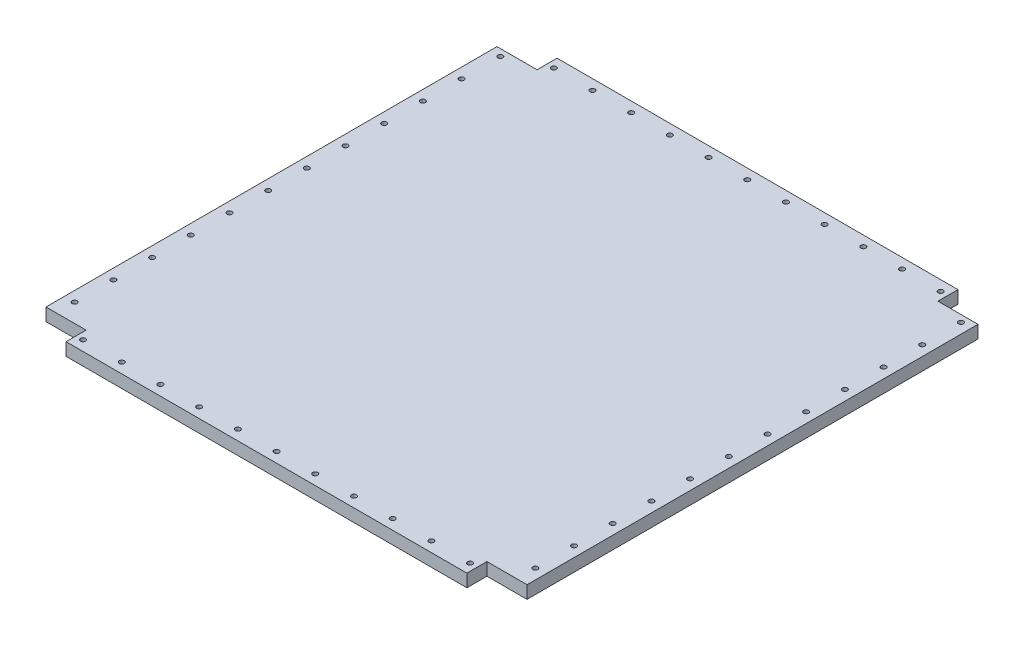
from build123d import *

# Parameters (mm, degrees)
BOSS_EXTRUDE1_DEPTH = 12.7
CUT_EXTRUDE1_START  = -13.7
SKETCH2_R           = 2.5
CUT_EXTRUDE1_DEPTH  = 14.7
LPATTERN1_COUNT     = 11
LPATTERN1_PITCH     = 38.608
CUT_EXTRUDE2_START  = -13.7
SKETCH3_R           = 2.5
CUT_EXTRUDE2_DEPTH  = 14.7
LPATTERN2_COUNT     = 11
LPATTERN2_PITCH     = 38.608
CUT_EXTRUDE3_START  = -13.7
SKETCH4_R           = 2.5
CUT_EXTRUDE3_DEPTH  = 14.7
LPATTERN3_COUNT     = 12
LPATTERN3_PITCH     = 38.608
CUT_EXTRUDE4_START  = -13.7
SKETCH5_R           = 2.5
CUT_EXTRUDE4_DEPTH  = 14.7
LPATTERN4_COUNT     = 12
LPATTERN4_PITCH     = 38.608


with BuildPart() as part:
    # Sketch1 → Boss-Extrude1 (new body)
    with BuildSketch(Plane(origin=(0, 0, 0), x_dir=(1, 0, 0), z_dir=(0, 1, 0))):
        Polygon((-199.53099264, 245.600086338), (200.46900736, 245.600086338), (200.46900736, 225.600086338), (240.46900736, 225.600086338), (240.46900736, -224.399913662), (200.46900736, -224.399913662), (200.46900736, -244.399913662), (-199.53099264, -244.399913662), (-199.53099264, -224.399913662), (-239.53099264, -224.399913662), (-239.53099264, 225.600086338), (-199.53099264, 225.600086338), align=None)
    extrude(amount=BOSS_EXTRUDE1_DEPTH)

    # Sketch2 → Cut-Extrude1 (cut)
    with BuildSketch(Plane(origin=(0, 12.7, 0), x_dir=(1, 0, 0), z_dir=(0, 1, 0)).offset(CUT_EXTRUDE1_START)):
        with Locations((-192.67299264, 235.440086338)):
            Circle(SKETCH2_R)
    cut_extrude1 = extrude(amount=CUT_EXTRUDE1_DEPTH, mode=Mode.SUBTRACT)

    # LPattern1: Cut-Extrude1 ×11
    with Locations(*[(i * LPATTERN1_PITCH, 0, 0) for i in range(1, LPATTERN1_COUNT)]):
        add(cut_extrude1, mode=Mode.SUBTRACT)

    # Sketch3 → Cut-Extrude2 (cut)
    with BuildSketch(Plane(origin=(0, 12.7, 0), x_dir=(1, 0, 0), z_dir=(0, 1, 0)).offset(CUT_EXTRUDE2_START)):
        with Locations((-192.67299264, -234.239913662)):
            Circle(SKETCH3_R)
    cut_extrude2 = extrude(amount=CUT_EXTRUDE2_DEPTH, mode=Mode.SUBTRACT)

    # LPattern2: Cut-Extrude2 ×11
    with Locations(*[(i * LPATTERN2_PITCH, 0, 0) for i in range(1, LPATTERN2_COUNT)]):
        add(cut_extrude2, mode=Mode.SUBTRACT)

    # Sketch4 → Cut-Extrude3 (cut)
    with BuildSketch(Plane(origin=(0, 12.7, 0), x_dir=(1, 0, 0), z_dir=(0, 1, 0)).offset(CUT_EXTRUDE3_START)):
        with Locations((230.30900736, 218.742086338)):
            Circle(SKETCH4_R)
    cut_extrude3 = extrude(amount=CUT_EXTRUDE3_DEPTH, mode=Mode.SUBTRACT)

    # LPattern3: Cut-Extrude3 ×12
    with Locations(*[(0, 0, i * LPATTERN3_PITCH) for i in range(1, LPATTERN3_COUNT)]):
        add(cut_extrude3, mode=Mode.SUBTRACT)

    # Sketch5 → Cut-Extrude4 (cut)
    with BuildSketch(Plane(origin=(0, 12.7, 0), x_dir=(1, 0, 0), z_dir=(0, 1, 0)).offset(CUT_EXTRUDE4_START)):
        with Locations((-229.37099264, 218.742086338)):
            Circle(SKETCH5_R)
    cut_extrude4 = extrude(amount=CUT_EXTRUDE4_DEPTH, mode=Mode.SUBTRACT)

    # LPattern4: Cut-Extrude4 ×12
    with Locations(*[(0, 0, i * LPATTERN4_PITCH) for i in range(1, LPATTERN4_COUNT)]):
        add(cut_extrude4, mode=Mode.SUBTRACT)


solid = part.part
